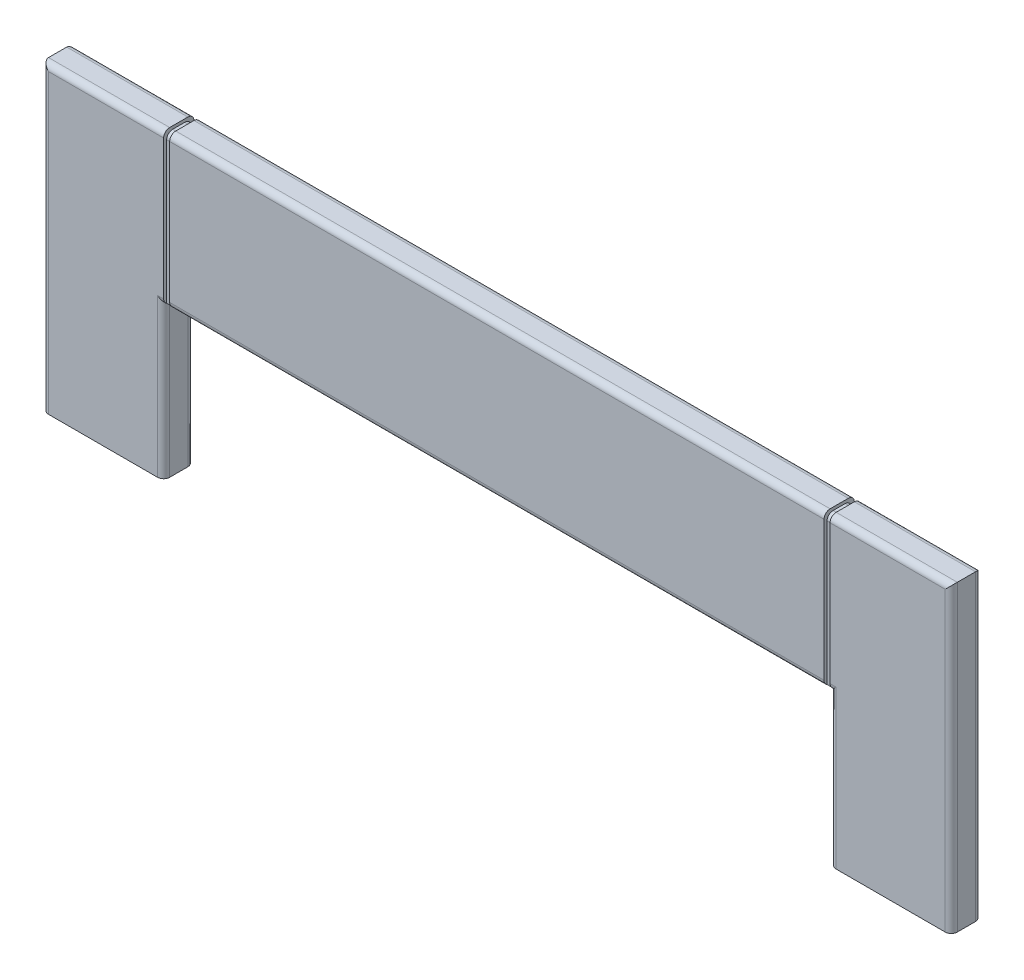
from build123d import *

# Parameters (mm, degrees)
BOSS_EXTRUDE1_DEPTH = 50
FILLET1_R           = 10
SKETCH2_W           = 10
SKETCH2_H           = 250
CUT_EXTRUDE4_DEPTH  = 5
SKETCH5_W           = 10
SKETCH5_H           = 5
CUT_EXTRUDE16_DEPTH = 200
SKETCH6_W           = 10
SKETCH6_H           = 5
CUT_EXTRUDE17_DEPTH = 50
FILLET2_R           = 10
FILLET3_R           = 10


with BuildPart() as part:
    # Sketch1 → Boss-Extrude1 (new body)
    with BuildSketch(Plane.XY):
        Polygon((-750, 0), (750, 0), (750, -500), (550, -500), (550, -250), (-550, -250), (-550, -500), (-750, -500), align=None)
    extrude(amount=BOSS_EXTRUDE1_DEPTH)

    # Fillet1
    fillet1_edges = [part.edges().sort_by_distance(p)[0] for p in [
        (0, -250, 0),
        (-550, -375, 0),
        (-750, -250, 0),
        (-550, -375, 50),
        (0, -250, 50),
        (550, -375, 50),
        (750, -250, 50),
        (0, 0, 50),
        (-750, -250, 50),
        (0, 0, 0),
        (750, -250, 0),
        (550, -375, 0),
    ]]
    fillet(fillet1_edges, radius=FILLET1_R)

    # Sketch2 → Cut-Extrude4 (cut)
    with BuildSketch(Plane.XY.offset(50)):
        with Locations((-545, -125)):
            Rectangle(SKETCH2_W, SKETCH2_H)
    cut_extrude4 = extrude(amount=-CUT_EXTRUDE4_DEPTH, mode=Mode.SUBTRACT)

    # Mirror1: Cut-Extrude4 across plane
    add(cut_extrude4.mirror(Plane(origin=(0, 0, 0), x_dir=(0, 0, 1), z_dir=(1, 0, 0))), mode=Mode.SUBTRACT)

    # Sketch5 → Cut-Extrude16 (cut)
    with BuildSketch(Plane(origin=(0, 0, 0), x_dir=(1, 0, 0), z_dir=(0, 1, 0))):
        with Locations((-545, -2.5)):
            Rectangle(SKETCH5_W, SKETCH5_H)
    cut_extrude16 = extrude(amount=-CUT_EXTRUDE16_DEPTH, mode=Mode.SUBTRACT)

    # Mirror5: Cut-Extrude16 across plane
    add(cut_extrude16.mirror(Plane(origin=(0, 0, 0), x_dir=(0, 0, 1), z_dir=(1, 0, 0))), mode=Mode.SUBTRACT)

    # Sketch6 → Cut-Extrude17 (cut)
    with BuildSketch(Plane.XY.offset(50)):
        with Locations((545, -2.5)):
            Rectangle(SKETCH6_W, SKETCH6_H)
    cut_extrude17 = extrude(amount=-CUT_EXTRUDE17_DEPTH, mode=Mode.SUBTRACT)

    # Fillet2
    fillet2_edges = [part.edges().sort_by_distance(p)[0] for p in [
        (545, -5, 45),
        (545, -5, 5),
    ]]
    fillet(fillet2_edges, radius=FILLET2_R)

    # Mirror8: Cut-Extrude17 across plane
    add(cut_extrude17.mirror(Plane(origin=(0, 0, 0), x_dir=(0, 0, 1), z_dir=(1, 0, 0))), mode=Mode.SUBTRACT)

    # Fillet3
    fillet3_edges = [part.edges().sort_by_distance(p)[0] for p in [
        (-545, -5, 5),
        (-545, -5, 45),
    ]]
    fillet(fillet3_edges, radius=FILLET3_R)


solid = part.part
